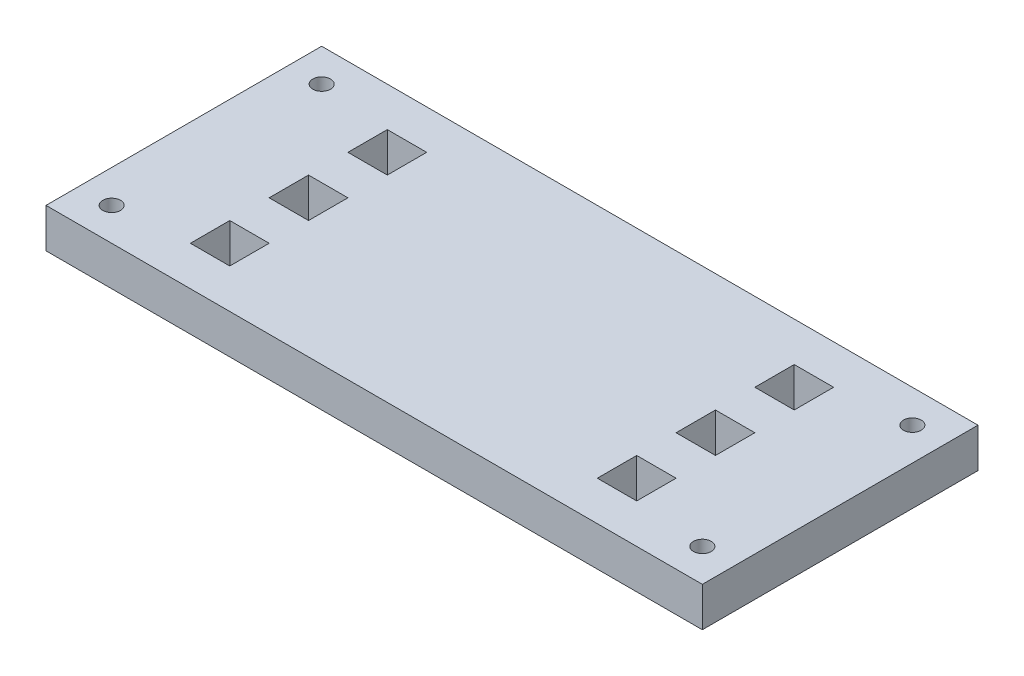
from build123d import *

# Parameters (mm, degrees)
SKETCH2_W           = 100
SKETCH2_H           = 42
SKETCH2_R           = 1.35
SKETCH2_W_2         = 6
SKETCH2_H_2         = 6
BOSS_EXTRUDE1_DEPTH = 6


with BuildPart() as part:
    # Sketch2 → Boss-Extrude1 (new body)
    with BuildSketch(Plane(origin=(0, 0, 0), x_dir=(1, 0, 0), z_dir=(0, 1, 0))):
        Rectangle(SKETCH2_W, SKETCH2_H)
        with Locations((-45, -16)):
            Circle(SKETCH2_R, mode=Mode.SUBTRACT)
        with Locations((-45, 16)):
            Circle(SKETCH2_R, mode=Mode.SUBTRACT)
        with Locations((45, 16)):
            Circle(SKETCH2_R, mode=Mode.SUBTRACT)
        with Locations((45, -16)):
            Circle(SKETCH2_R, mode=Mode.SUBTRACT)
        with Locations((-31, -12)):
            Rectangle(SKETCH2_W_2, SKETCH2_H_2, mode=Mode.SUBTRACT)
        with Locations((-31, 0)):
            Rectangle(SKETCH2_W_2, SKETCH2_H_2, mode=Mode.SUBTRACT)
        with Locations((-31, 12)):
            Rectangle(SKETCH2_W_2, SKETCH2_H_2, mode=Mode.SUBTRACT)
        with Locations((31, -12)):
            Rectangle(SKETCH2_W_2, SKETCH2_H_2, mode=Mode.SUBTRACT)
        with Locations((31, 0)):
            Rectangle(SKETCH2_W_2, SKETCH2_H_2, mode=Mode.SUBTRACT)
        with Locations((31, 12)):
            Rectangle(SKETCH2_W_2, SKETCH2_H_2, mode=Mode.SUBTRACT)
    extrude(amount=BOSS_EXTRUDE1_DEPTH)


solid = part.part
